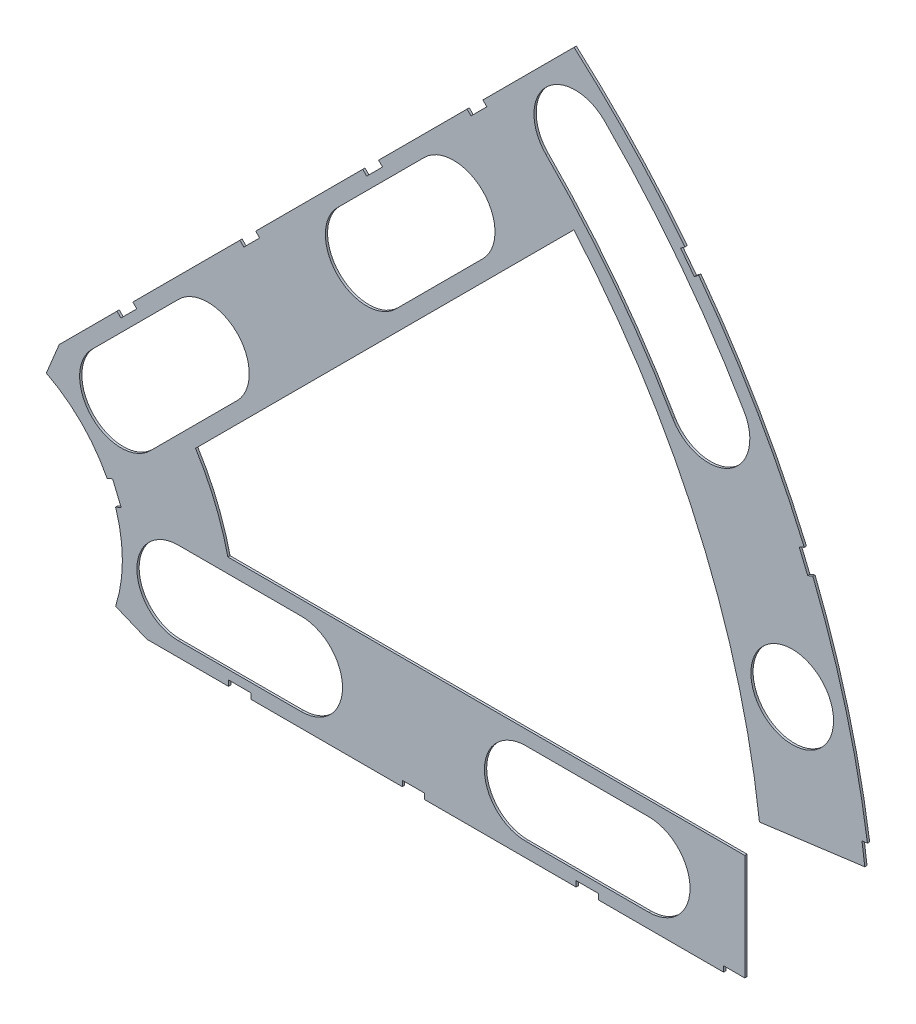
from build123d import *

# Parameters (mm, degrees)
BOSS_EXTRUDE1_DEPTH = 0.254
SKETCH2_R           = 4.699
CUT_EXTRUDE1_DEPTH  = 1.254
SKETCH3_W           = 2.54
SKETCH3_H           = 0.635
CUT_EXTRUDE2_DEPTH  = 1.254
CUT_EXTRUDE4_DEPTH  = 1.254
CUT_EXTRUDE5_DEPTH  = 1.254


with BuildPart() as part:
    # Sketch1 → Boss-Extrude1 (new body)
    with BuildSketch(Plane.XY):
        with BuildLine():
            Line((67.21146711, 76.191723231), (8.696654013, 17.676910134))
            Line((8.696654013, 17.676910134), (7.228954972, 14.133571205))
            ThreePointArc((7.228954972, 14.133571205), (14.666587579, 6.075099489), (15.105587123, -4.88230096))
            Line((15.105587123, -4.88230096), (18.648926052, -6.35))
            Line((18.648926052, -6.35), (101.401368334, -6.35))
            ThreePointArc((101.401368334, -6.35), (93.866160503, 38.880636728), (67.21146711, 76.191723231))
        make_face()
        with BuildLine():
            Line((88.672924278, 6.35), (27.86051193, 6.35))
            ThreePointArc((27.86051193, 6.35), (26.399857642, 10.93517908), (24.190484974, 15.210228852))
            Line((24.190484974, 15.210228852), (67.191354125, 58.211098004))
            ThreePointArc((67.191354125, 58.211098004), (82.13289044, 34.020557137), (88.672924278, 6.35))
        make_face(mode=Mode.SUBTRACT)
    extrude(amount=BOSS_EXTRUDE1_DEPTH)

    # Sketch2 → Cut-Extrude1 (cut, through all)
    with BuildSketch(Plane.XY.offset(0.254)):
        with Locations((22.225, 0)):
            Circle(SKETCH2_R)
        with Locations((36.195, 0)):
            Circle(SKETCH2_R)
        with Locations((61.722, 0)):
            Circle(SKETCH2_R)
        with Locations((75.692, 0)):
            Circle(SKETCH2_R)
        with Locations((95.25, 0)):
            Circle(SKETCH2_R)
        with Locations((15.715448212, 15.715448212)):
            Circle(SKETCH2_R)
        with Locations((25.593729945, 25.593729945)):
            Circle(SKETCH2_R)
        with Locations((43.644044748, 43.644044748)):
            Circle(SKETCH2_R)
        with Locations((53.522326482, 53.522326482)):
            Circle(SKETCH2_R)
        with Locations((92.004434954, 24.652514046)):
            Circle(SKETCH2_R)
        with Locations((82.48891971, 47.625)):
            Circle(SKETCH2_R)
        with Locations((67.351920908, 67.351920908)):
            Circle(SKETCH2_R)
    extrude(amount=-CUT_EXTRUDE1_DEPTH, mode=Mode.SUBTRACT)

    # Sketch3 → Cut-Extrude2 (cut, through all)
    with BuildSketch(Plane.XY.offset(0.254)):
        Polygon((15.266435406, 24.246691527), (17.06248663, 26.042742751), (17.511499436, 25.593729945), (15.715448212, 23.797678721), align=None)
        Polygon((44.991083167, 53.971339288), (43.195031942, 52.175288063), (43.644044748, 51.726275257), (45.440095973, 53.522326482), align=None)
        with Locations((29.21, -6.0325)):
            Rectangle(SKETCH3_W, SKETCH3_H)
        with Locations((68.707, -6.0325)):
            Rectangle(SKETCH3_W, SKETCH3_H)
        Polygon((29.230733674, 38.210989795), (31.026784898, 40.007041019), (31.475797704, 39.558028213), (29.67974648, 37.761976989), align=None)
        Polygon((56.845021246, 65.825277367), (55.048970022, 64.029226143), (55.497982828, 63.580213337), (57.294034052, 65.376264561), align=None)
        with Locations((48.9585, -6.0325)):
            Rectangle(SKETCH3_W, SKETCH3_H)
        with Locations((85.471, -6.0325)):
            Rectangle(SKETCH3_W, SKETCH3_H)
        Polygon((99.935462164, 14.437711971), (100.266998693, 11.919442024), (101.526133667, 12.085210288), (101.194597138, 14.603480236), align=None)
        Polygon((93.765504959, 37.464305742), (94.938831965, 37.950313702), (93.966816047, 40.296967714), (92.793489041, 39.810959755), align=None)
        Polygon((79.327792988, 62.471156422), (80.874047017, 60.456038938), (81.88160576, 61.229165953), (80.33535173, 63.244283437), align=None)
        Polygon((13.593916116, 7.005422516), (14.565932035, 4.658768503), (15.739259041, 5.144776462), (14.767243123, 7.491430475), align=None)
    extrude(amount=-CUT_EXTRUDE2_DEPTH, mode=Mode.SUBTRACT)

    # Sketch6 → Cut-Extrude4 (cut, through all)
    with BuildSketch(Plane.XY.offset(0.254)):
        with BuildLine():
            Line((12.392753447, 19.038142977), (22.27103518, 28.91642471))
            ThreePointArc((22.27103518, 28.91642471), (28.91642471, 28.91642471), (28.91642471, 22.27103518))
            Line((28.91642471, 22.27103518), (19.038142977, 12.392753447))
            ThreePointArc((19.038142977, 12.392753447), (12.392753447, 12.392753447), (12.392753447, 19.038142977))
        make_face()
        with BuildLine():
            Line((40.321349984, 46.966739513), (50.199631717, 56.845021246))
            ThreePointArc((50.199631717, 56.845021246), (56.845021246, 56.845021246), (56.845021246, 50.199631717))
            Line((56.845021246, 50.199631717), (46.966739513, 40.321349984))
            ThreePointArc((46.966739513, 40.321349984), (40.321349984, 40.321349984), (40.321349984, 46.966739513))
        make_face()
        with BuildLine():
            Line((22.225, 4.699), (36.195, 4.699))
            ThreePointArc((36.195, 4.699), (40.894, 0), (36.195, -4.699))
            Line((36.195, -4.699), (22.225, -4.699))
            ThreePointArc((22.225, -4.699), (17.526, 0), (22.225, 4.699))
        make_face()
        with BuildLine():
            Line((61.722, 4.699), (75.692, 4.699))
            ThreePointArc((75.692, 4.699), (80.391, 0), (75.692, -4.699))
            Line((75.692, -4.699), (61.722, -4.699))
            ThreePointArc((61.722, -4.699), (57.023, 0), (61.722, 4.699))
        make_face()
        with BuildLine():
            ThreePointArc((86.558373083, 49.9745), (79.294873009, 60.845096068), (70.674615673, 70.674615673))
            ThreePointArc((70.674615673, 70.674615673), (64.029226143, 70.674615673), (64.029226143, 64.029226143))
            ThreePointArc((64.029226143, 64.029226143), (71.838938317, 55.123956158), (78.419466338, 45.2755))
            ThreePointArc((78.419466338, 45.2755), (84.83841971, 43.555546628), (86.558373083, 49.9745))
        make_face()
    extrude(amount=-CUT_EXTRUDE4_DEPTH, mode=Mode.SUBTRACT)

    # Sketch5 → Cut-Extrude5 (cut, through all)
    with BuildSketch(Plane.XY.offset(0.254)):
        Polygon((86.614, -7.62), (86.614, 10.250086524), (102.87, 12.390229525), (102.87, -7.62), align=None)
    extrude(amount=-CUT_EXTRUDE5_DEPTH, mode=Mode.SUBTRACT)


solid = part.part
